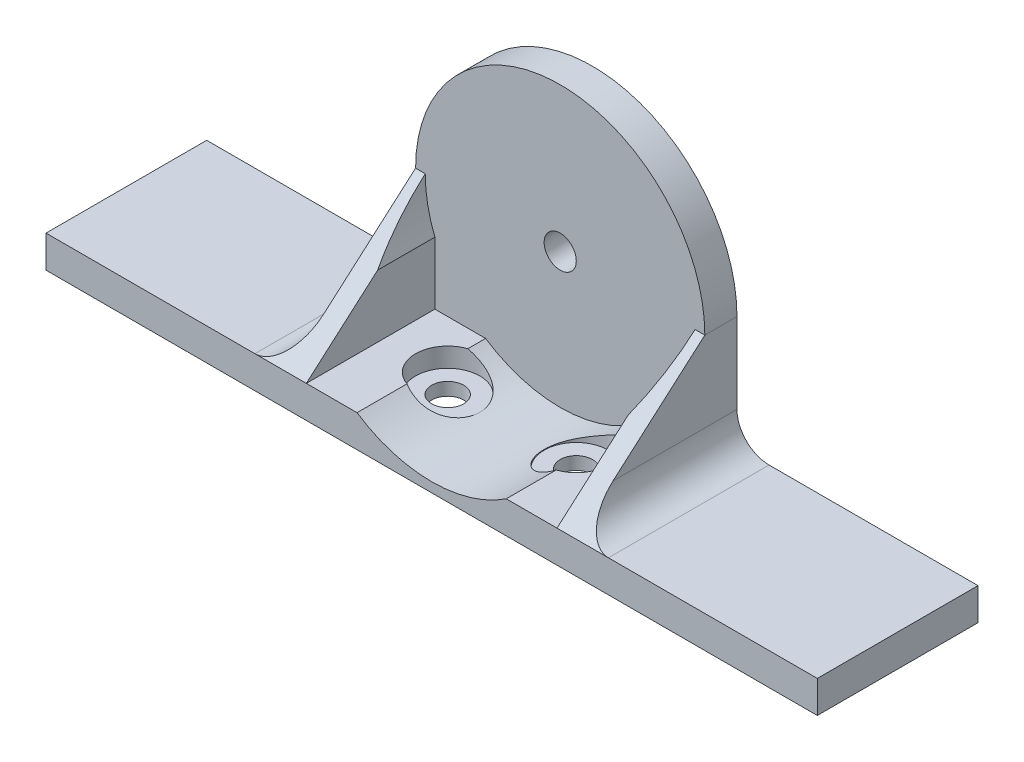
from build123d import *

# Parameters (mm, degrees)
SKETCH2_R           = 22.5
BOSS_EXTRUDE3_DEPTH = 25
SKETCH6_W           = 45
SKETCH6_H           = 22.5
BOSS_EXTRUDE4_DEPTH = 25
SKETCH4_R           = 20
CUT_EXTRUDE1_DEPTH  = 20
SKETCH5_R           = 2.5
CUT_EXTRUDE2_DEPTH  = 5
SKETCH7_R           = 5
CUT_EXTRUDE6_DEPTH  = 46
SKETCH9_R           = 5
SKETCH9_R_2         = 2.5
BOSS_EXTRUDE5_DEPTH = 2
SKETCH14_W          = 15
SKETCH14_H          = 5
CUT_EXTRUDE8_DEPTH  = 46.0000001
SKETCH15_W          = 25
SKETCH15_H          = 5
BOSS_EXTRUDE6_DEPTH = 37.5
SKETCH16_W          = 25
SKETCH16_H          = 5
BOSS_EXTRUDE7_DEPTH = 37.5
SKETCH19_W          = 50
SKETCH19_H          = 50
CUT_EXTRUDE9_DEPTH  = 20
BOSS_EXTRUDE8_DEPTH = 3
BOSS_EXTRUDE9_DEPTH = 3
SKETCH22_R          = 21
CUT_EXTRUDE10_DEPTH = 21.0000001
FILLET2_R           = 5


with BuildPart() as part:
    # Sketch2 → Boss-Extrude3 (new body)
    with BuildSketch(Plane.XY):
        Circle(SKETCH2_R)
    extrude(amount=BOSS_EXTRUDE3_DEPTH)

    # Sketch6 → Boss-Extrude4 (add)
    with BuildSketch(Plane.XY):
        with Locations((0, -11.25)):
            Rectangle(SKETCH6_W, SKETCH6_H)
    extrude(amount=BOSS_EXTRUDE4_DEPTH)

    # Sketch4 → Cut-Extrude1 (cut)
    with BuildSketch(Plane.XY.offset(25)):
        Circle(SKETCH4_R)
    extrude(amount=-CUT_EXTRUDE1_DEPTH, mode=Mode.SUBTRACT)

    # Sketch5 → Cut-Extrude2 (cut)
    with BuildSketch(Plane(origin=(0, 0, 0), x_dir=(-1, 0, 0), z_dir=(0, 0, -1))):
        Circle(SKETCH5_R)
    extrude(amount=-CUT_EXTRUDE2_DEPTH, mode=Mode.SUBTRACT)

    # Sketch7 → Cut-Extrude6 (cut, through all)
    with BuildSketch(Plane.XZ.offset(22.5)):
        with Locations((-10, 12.5)):
            Circle(SKETCH7_R)
        with Locations((10, 12.5)):
            Circle(SKETCH7_R)
    extrude(amount=-CUT_EXTRUDE6_DEPTH, mode=Mode.SUBTRACT)

    # Sketch9 → Boss-Extrude5 (add)
    with BuildSketch(Plane.XZ.offset(22.5)):
        with Locations((-10, 12.5)):
            Circle(SKETCH9_R)
        with Locations((-10, 12.5)):
            Circle(SKETCH9_R_2, mode=Mode.SUBTRACT)
        with Locations((10, 12.5)):
            Circle(SKETCH9_R)
        with Locations((10, 12.5)):
            Circle(SKETCH9_R_2, mode=Mode.SUBTRACT)
    extrude(amount=-BOSS_EXTRUDE5_DEPTH)

    # Sketch14 → Cut-Extrude8 (cut, through all)
    with BuildSketch(Plane(origin=(22.5, 0, 0), x_dir=(0, 0, -1), z_dir=(1, 0, 0))):
        with Locations((-12.5, 0)):
            Rectangle(SKETCH14_W, SKETCH14_H)
    extrude(amount=-CUT_EXTRUDE8_DEPTH, mode=Mode.SUBTRACT)

    # Sketch15 → Boss-Extrude6 (add)
    with BuildSketch(Plane.ZY.offset(22.5)):
        with Locations((12.5, -20)):
            Rectangle(SKETCH15_W, SKETCH15_H)
    extrude(amount=BOSS_EXTRUDE6_DEPTH)

    # Sketch16 → Boss-Extrude7 (add)
    with BuildSketch(Plane(origin=(22.5, 0, 0), x_dir=(0, 0, -1), z_dir=(1, 0, 0))):
        with Locations((-12.5, -20)):
            Rectangle(SKETCH16_W, SKETCH16_H)
    extrude(amount=BOSS_EXTRUDE7_DEPTH)

    # Sketch19 → Cut-Extrude9 (cut)
    with BuildSketch(Plane.XY.offset(25)):
        with Locations((2.5, 7.5)):
            Rectangle(SKETCH19_W, SKETCH19_H)
    extrude(amount=-CUT_EXTRUDE9_DEPTH, mode=Mode.SUBTRACT)

    # Sketch24 → Boss-Extrude8 (add)
    with BuildSketch(Plane.ZY.offset(22.5)):
        Polygon((5, 0), (5, -17.5), (25, -17.5), align=None)
    extrude(amount=-BOSS_EXTRUDE8_DEPTH)

    # Sketch25 → Boss-Extrude9 (add)
    with BuildSketch(Plane(origin=(22.5, 0, 0), x_dir=(0, 0, -1), z_dir=(1, 0, 0))):
        Polygon((-5, 0), (-25, -17.5), (-5, -17.5), align=None)
    extrude(amount=-BOSS_EXTRUDE9_DEPTH)

    # Sketch22 → Cut-Extrude10 (cut, through all)
    with BuildSketch(Plane.XY.offset(5)):
        Circle(SKETCH22_R)
    extrude(amount=CUT_EXTRUDE10_DEPTH, mode=Mode.SUBTRACT)

    # Fillet2
    fillet2_edges = [part.edges().sort_by_distance(p)[0] for p in [
        (22.5, -17.5, 12.5),
        (-22.5, -17.5, 12.5),
    ]]
    fillet(fillet2_edges, radius=FILLET2_R)


solid = part.part
